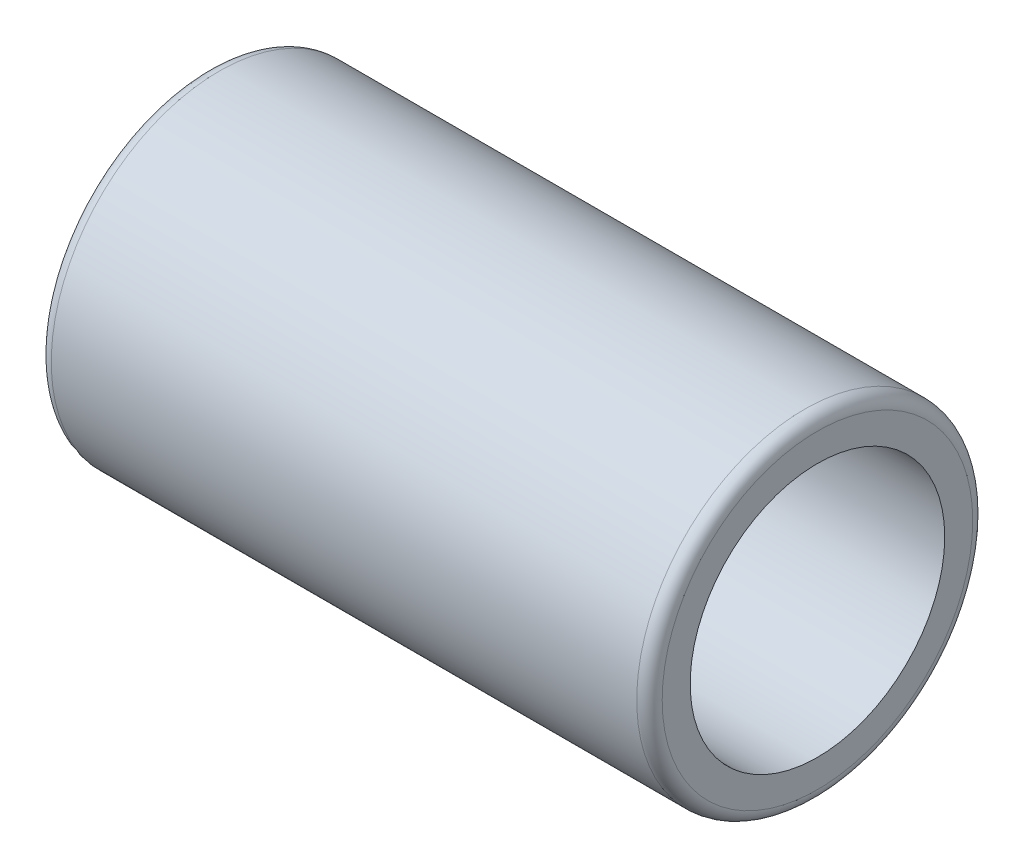
from build123d import *

# Parameters (mm, degrees)
EXTRUDE1_START = -12
SKETCH1_R      = 6.6
SKETCH1_R_2    = 5
EXTRUDE1_DEPTH = 24
FILLET1_R      = 0.5


with BuildPart() as part:
    # Sketch1 → Extrude1 (new body)
    with BuildSketch(Plane(origin=(0, 0, 0), x_dir=(0, 0, -1), z_dir=(1, 0, 0)).offset(EXTRUDE1_START)):
        Circle(SKETCH1_R)
        Circle(SKETCH1_R_2, mode=Mode.SUBTRACT)
    extrude(amount=EXTRUDE1_DEPTH)

    # Fillet1
    fillet1_edges = [part.edges().sort_by_distance(p)[0] for p in [
        (-12, 0, 6.6),
        (12, 0, 6.6),
    ]]
    fillet(fillet1_edges, radius=FILLET1_R)


solid = part.part
